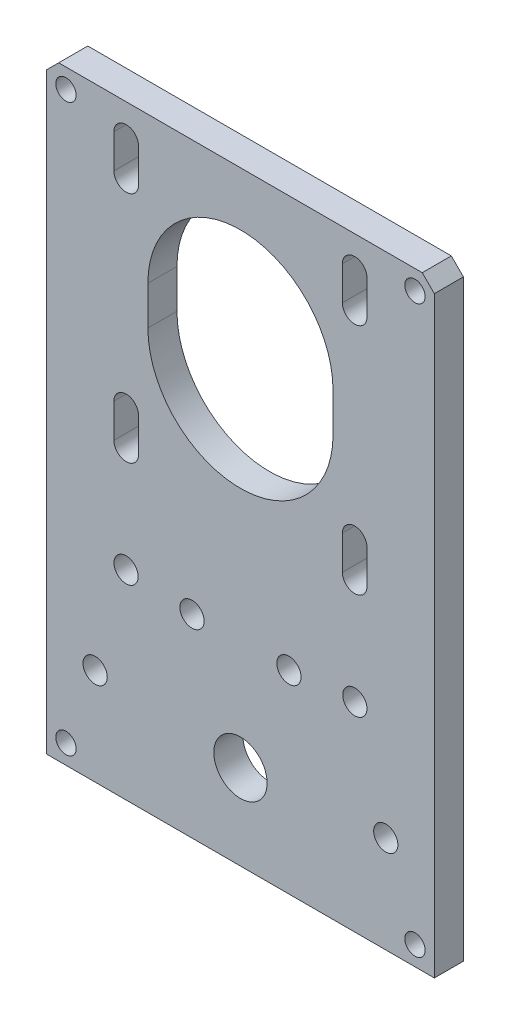
from build123d import *

# Parameters (mm, degrees)
SKETCH1_W                = 80
SKETCH1_H                = 124.77
SKETCH1_R                = 5.5
BOSS_EXTRUDE1_DEPTH      = 6
F_5_0_5_DIAMETER_HOLE1_D = 5
M5X0_8_TAPPED_HOLE1_D    = 4.2
CHAMFER1_SIZE            = 2.5


with BuildPart() as part:
    # Sketch1 → Boss-Extrude1 (new body)
    with BuildSketch(Plane.XY):
        with Locations((40, 62.385)):
            Rectangle(SKETCH1_W, SKETCH1_H)
        with Locations((40, 17.57)):
            Circle(SKETCH1_R, mode=Mode.SUBTRACT)
        with BuildLine():
            Line((59.1, 94.58), (59.1, 86.58))
            ThreePointArc((59.1, 86.58), (40, 67.48), (20.9, 86.58))
            Line((20.9, 86.58), (20.9, 94.58))
            ThreePointArc((20.9, 94.58), (40, 113.68), (59.1, 94.58))
        make_face(mode=Mode.SUBTRACT)
        with BuildLine():
            Line((18.97, 118.15), (18.97, 111.15))
            ThreePointArc((18.97, 111.15), (16.43, 108.61), (13.89, 111.15))
            Line((13.89, 111.15), (13.89, 118.15))
            ThreePointArc((13.89, 118.15), (16.43, 120.69), (18.97, 118.15))
        make_face(mode=Mode.SUBTRACT)
        with BuildLine():
            Line((61.03, 118.15), (61.03, 111.15))
            ThreePointArc((61.03, 111.15), (63.57, 108.61), (66.11, 111.15))
            Line((66.11, 111.15), (66.11, 118.15))
            ThreePointArc((66.11, 118.15), (63.57, 120.69), (61.03, 118.15))
        make_face(mode=Mode.SUBTRACT)
        with BuildLine():
            Line((18.97, 63.01), (18.97, 70.01))
            ThreePointArc((18.97, 70.01), (16.43, 72.55), (13.89, 70.01))
            Line((13.89, 70.01), (13.89, 63.01))
            ThreePointArc((13.89, 63.01), (16.43, 60.47), (18.97, 63.01))
        make_face(mode=Mode.SUBTRACT)
        with BuildLine():
            Line((61.03, 63.01), (61.03, 70.01))
            ThreePointArc((61.03, 70.01), (63.57, 72.55), (66.11, 70.01))
            Line((66.11, 70.01), (66.11, 63.01))
            ThreePointArc((66.11, 63.01), (63.57, 60.47), (61.03, 63.01))
        make_face(mode=Mode.SUBTRACT)
    extrude(amount=BOSS_EXTRUDE1_DEPTH)

    # Ø5.0 (5) Diameter Hole1 (through all)
    with Locations(Plane.XY.offset(6)):
        with Locations((10.02, 20), (16.4, 41.14), (30, 40), (50, 40), (63.6, 41.14), (69.98, 20)):
            Hole(F_5_0_5_DIAMETER_HOLE1_D / 2)

    # M5x0.8 Tapped Hole1 (through all)
    with Locations(Plane.XY.offset(6)):
        with Locations((4, 120.77), (76, 120.77), (76, 4), (4, 4)):
            Hole(M5X0_8_TAPPED_HOLE1_D / 2)

    # Chamfer1
    chamfer1_edges = [part.edges().sort_by_distance(p)[0] for p in [
        (0, 124.77, 3),
        (80, 124.77, 3),
    ]]
    chamfer(chamfer1_edges, length=CHAMFER1_SIZE)


solid = part.part
